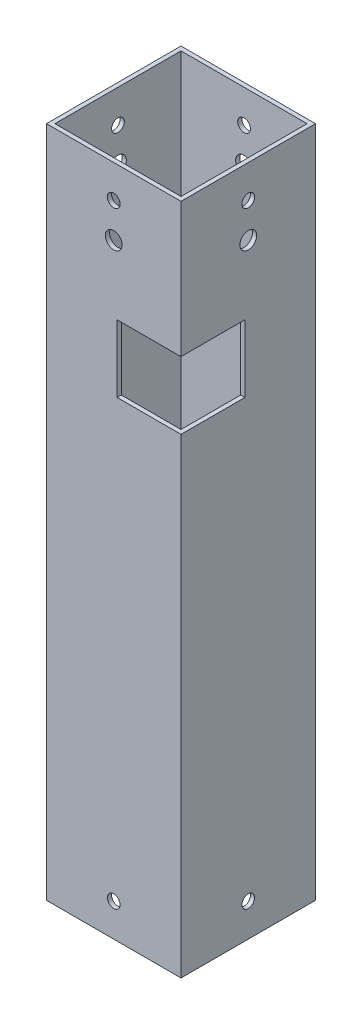
from build123d import *

# Parameters (mm, degrees)
SKETCH1_W               = 50.8
SKETCH1_H               = 50.8
SKETCH1_W_2             = 47.625
SKETCH1_H_2             = 47.625
BOSS_EXTRUDE1_DEPTH     = 254
SKETCH4_R               = 2.3999952
CUT_EXTRUDE1_DEPTH      = 50.2125
CUT_EXTRUDE1_DEPTH_BACK = 2.5875
SKETCH5_R               = 2.3999952
CUT_EXTRUDE2_DEPTH      = 51.8
SKETCH6_R               = 2.3999952
CUT_EXTRUDE3_DEPTH      = 1
CUT_EXTRUDE3_DEPTH_BACK = 51.8
SKETCH7_R               = 2.3999952
CUT_EXTRUDE4_DEPTH      = 1
CUT_EXTRUDE4_DEPTH_BACK = 51.8
SKETCH8_R               = 3.175
CUT_EXTRUDE5_DEPTH      = 1
CUT_EXTRUDE5_DEPTH_BACK = 51.8
SKETCH9_R               = 3.175
CUT_EXTRUDE6_DEPTH      = 1
CUT_EXTRUDE6_DEPTH_BACK = 51.8
SKETCH10_W              = 24.13
SKETCH10_H              = 25.4
CUT_EXTRUDE7_DEPTH      = 24.13


with BuildPart() as part:
    # Sketch1 → Boss-Extrude1 (new body)
    with BuildSketch(Plane(origin=(0, 0, 0), x_dir=(1, 0, 0), z_dir=(0, 1, 0))):
        Rectangle(SKETCH1_W, SKETCH1_H)
        Rectangle(SKETCH1_W_2, SKETCH1_H_2, mode=Mode.SUBTRACT)
    extrude(amount=BOSS_EXTRUDE1_DEPTH)

    # Sketch4 → Cut-Extrude1 (cut, two sides)
    with BuildSketch(Plane(origin=(-23.8125, 0, 0), x_dir=(0, 0, -1), z_dir=(1, 0, 0))) as cut_extrude1_sk:
        with Locations((0, 241.587599882)):
            Circle(SKETCH4_R)
    extrude(amount=CUT_EXTRUDE1_DEPTH, mode=Mode.SUBTRACT)
    extrude(cut_extrude1_sk.sketch, amount=-CUT_EXTRUDE1_DEPTH_BACK, mode=Mode.SUBTRACT)

    # Sketch5 → Cut-Extrude2 (cut, through all)
    with BuildSketch(Plane(origin=(0, 0, -25.4), x_dir=(-1, 0, 0), z_dir=(0, 0, -1))):
        with Locations((0, 241.587599882)):
            Circle(SKETCH5_R)
    extrude(amount=-CUT_EXTRUDE2_DEPTH, mode=Mode.SUBTRACT)

    # Sketch6 → Cut-Extrude3 (cut, two sides)
    with BuildSketch(Plane(origin=(25.4, 0, 0), x_dir=(0, 0, -1), z_dir=(1, 0, 0))) as cut_extrude3_sk:
        with Locations((0, 12.412400118)):
            Circle(SKETCH6_R)
    extrude(amount=CUT_EXTRUDE3_DEPTH, mode=Mode.SUBTRACT)
    extrude(cut_extrude3_sk.sketch, amount=-CUT_EXTRUDE3_DEPTH_BACK, mode=Mode.SUBTRACT)

    # Sketch7 → Cut-Extrude4 (cut, two sides)
    with BuildSketch(Plane(origin=(0, 0, -25.4), x_dir=(-1, 0, 0), z_dir=(0, 0, -1))) as cut_extrude4_sk:
        with Locations((0, 12.412400118)):
            Circle(SKETCH7_R)
    extrude(amount=CUT_EXTRUDE4_DEPTH, mode=Mode.SUBTRACT)
    extrude(cut_extrude4_sk.sketch, amount=-CUT_EXTRUDE4_DEPTH_BACK, mode=Mode.SUBTRACT)

    # Sketch8 → Cut-Extrude5 (cut, two sides)
    with BuildSketch(Plane(origin=(0, 0, -25.4), x_dir=(-1, 0, 0), z_dir=(0, 0, -1))) as cut_extrude5_sk:
        with Locations((0, 228.6)):
            Circle(SKETCH8_R)
    extrude(amount=CUT_EXTRUDE5_DEPTH, mode=Mode.SUBTRACT)
    extrude(cut_extrude5_sk.sketch, amount=-CUT_EXTRUDE5_DEPTH_BACK, mode=Mode.SUBTRACT)

    # Sketch9 → Cut-Extrude6 (cut, two sides)
    with BuildSketch(Plane(origin=(25.4, 0, 0), x_dir=(0, 0, -1), z_dir=(1, 0, 0))) as cut_extrude6_sk:
        with Locations((0, 228.6)):
            Circle(SKETCH9_R)
    extrude(amount=CUT_EXTRUDE6_DEPTH, mode=Mode.SUBTRACT)
    extrude(cut_extrude6_sk.sketch, amount=-CUT_EXTRUDE6_DEPTH_BACK, mode=Mode.SUBTRACT)

    # Sketch10 → Cut-Extrude7 (cut)
    with BuildSketch(Plane(origin=(25.4, 0, 0), x_dir=(0, 0, -1), z_dir=(1, 0, 0))):
        with Locations((-13.335, 190.5)):
            Rectangle(SKETCH10_W, SKETCH10_H)
    extrude(amount=-CUT_EXTRUDE7_DEPTH, mode=Mode.SUBTRACT)


solid = part.part
